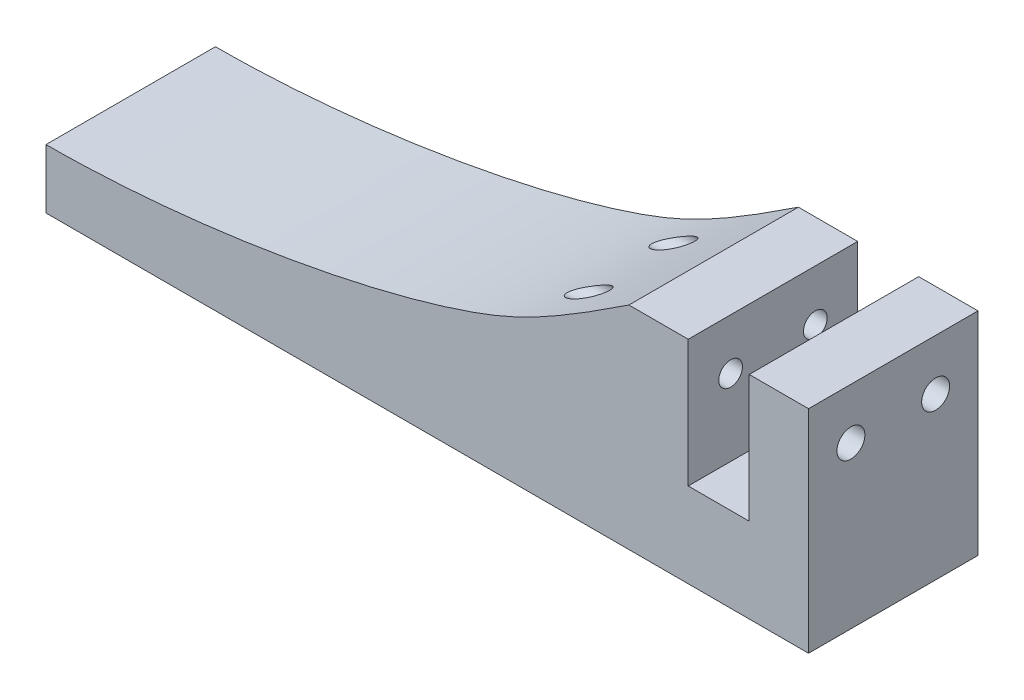
from build123d import *

# Parameters (mm, degrees)
BOSS_EXTRUDE1_DEPTH = 20
SKETCH2_R           = 1.65
CUT_EXTRUDE1_DEPTH  = 7
SKETCH3_R           = 1.4
CUT_EXTRUDE2_DEPTH  = 27


with BuildPart() as part:
    # Sketch1 → Boss-Extrude1 (new body)
    with BuildSketch(Plane.XY):
        with BuildLine():
            Line((0, 123.395512055), (0, 108.395512055))
            Line((0, 108.395512055), (-7.2, 108.395512055))
            Line((-7.2, 108.395512055), (-7.2, 123.395512055))
            Line((-7.2, 123.395512055), (-14.2, 123.395512055))
            add(Edge.make_bspline(
                [(-14.2, 123.395512055), (-23.530576474, 117.205565192), (-38.446210931, 109.915945525), (-66.691471381, 105.395512055), (-83, 105.395512055)],
                knots=[0, 0, 0, 0, 0.267223526, 1, 1, 1, 1], degree=3))
            Line((-83, 105.395512055), (-83, 98.395512055))
            Line((-83, 98.395512055), (7, 98.395512055))
            Line((7, 98.395512055), (7, 123.395512055))
            Line((7, 123.395512055), (0, 123.395512055))
        make_face()
    extrude(amount=BOSS_EXTRUDE1_DEPTH)

    # Sketch2 → Cut-Extrude1 (cut)
    with BuildSketch(Plane(origin=(7, 0, 0), x_dir=(0, 0, -1), z_dir=(1, 0, 0))):
        with Locations((-15, 117.395512055)):
            Circle(SKETCH2_R)
        with Locations((-5, 117.395512055)):
            Circle(SKETCH2_R)
    extrude(amount=-CUT_EXTRUDE1_DEPTH, mode=Mode.SUBTRACT)

    # Sketch3 → Cut-Extrude2 (cut)
    with BuildSketch(Plane(origin=(-7.2, 0, 0), x_dir=(0, 0, -1), z_dir=(1, 0, 0))):
        with Locations((-15, 117.395512055)):
            Circle(SKETCH3_R)
        with Locations((-5, 117.395512055)):
            Circle(SKETCH3_R)
    extrude(amount=-CUT_EXTRUDE2_DEPTH, mode=Mode.SUBTRACT)


solid = part.part
